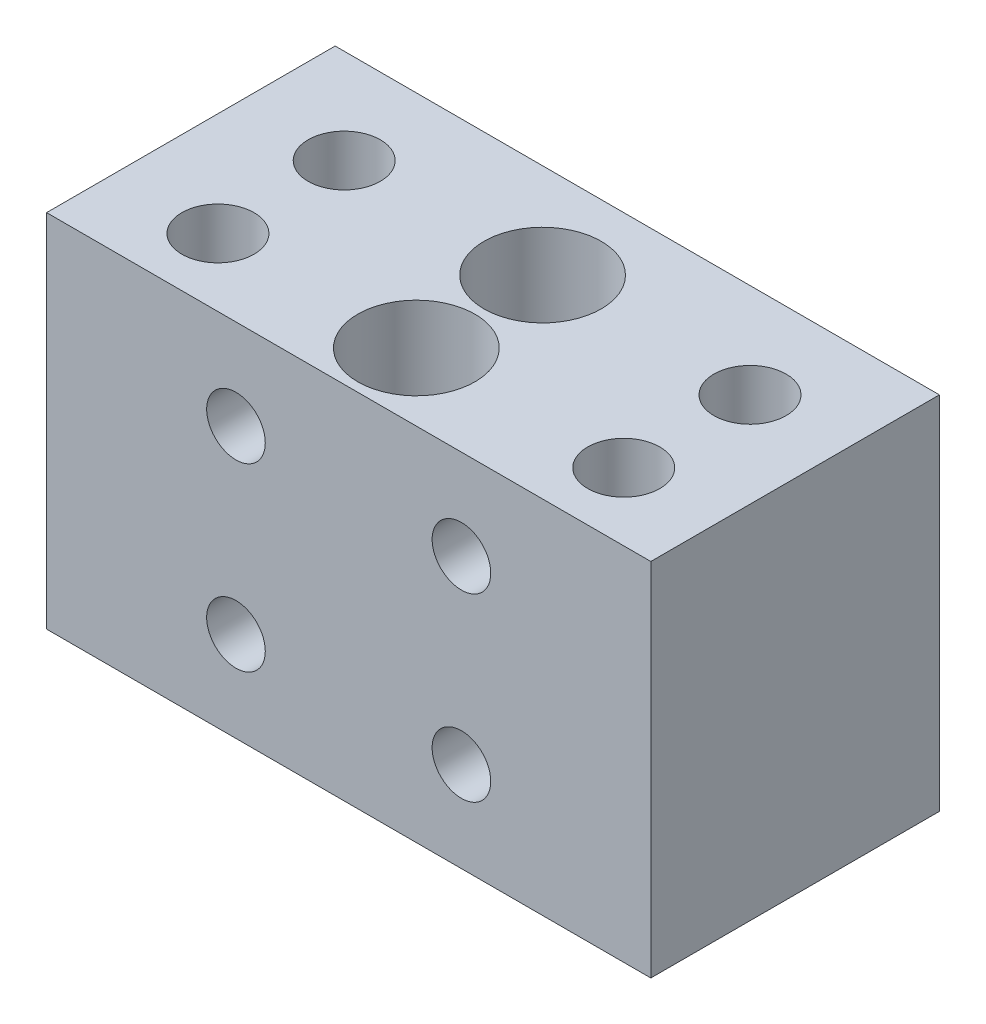
from build123d import *

# Parameters (mm, degrees)
SKETCH1_W                      = 67
SKETCH1_H                      = 40
BOSS_EXTRUDE1_DEPTH            = 32
SKETCH2_R                      = 6
CUT_EXTRUDE1_DEPTH             = 19
SKETCH4_R                      = 4
CUT_EXTRUDE2_DEPTH             = 22
LPATTERN1_COUNT                = 2
LPATTERN1_PITCH                = 45
LPATTERN1_COUNT_DIR2           = 2
LPATTERN1_PITCH_DIR2           = 14
SKETCH5_R                      = 6.5
CUT_EXTRUDE3_DEPTH             = 35
M4X0_7_TAPPED_HOLE1_D          = 3.3
CBORE_FOR_M3_SHCS1_D           = 3.4
CBORE_FOR_M3_SHCS1_CBORE_D     = 6.5
CBORE_FOR_M3_SHCS1_CBORE_DEPTH = 30
LPATTERN2_COUNT                = 2
LPATTERN2_PITCH                = 25
LPATTERN2_COUNT_DIR2           = 2
LPATTERN2_PITCH_DIR2           = 20
M3X0_5_TAPPED_HOLE1_D          = 2.5
M3X0_5_TAPPED_HOLE1_DEPTH      = 5.5
M3X0_5_TAPPED_HOLE1_TIP        = 0.751075774


with BuildPart() as part:
    # Sketch1 → Boss-Extrude1 (new body)
    with BuildSketch(Plane.XY):
        with Locations((33.5, 20)):
            Rectangle(SKETCH1_W, SKETCH1_H)
    extrude(amount=BOSS_EXTRUDE1_DEPTH)

    # Sketch2 → Cut-Extrude1 (cut)
    with BuildSketch(Plane.XZ):
        with Locations((11.5, 24.5)):
            Circle(SKETCH2_R)
    cut_extrude1 = extrude(amount=-CUT_EXTRUDE1_DEPTH, mode=Mode.SUBTRACT)

    # Sketch4 → Cut-Extrude2 (cut, through all)
    with BuildSketch(Plane.XZ.offset(-19)):
        with Locations((11.5, 24.5)):
            Circle(SKETCH4_R)
    cut_extrude2 = extrude(amount=-CUT_EXTRUDE2_DEPTH, mode=Mode.SUBTRACT)

    # LPattern1: Cut-Extrude1, Cut-Extrude2 2 × 2
    with Locations(*[(i * LPATTERN1_PITCH, 0, -j * LPATTERN1_PITCH_DIR2) for i in range(LPATTERN1_COUNT) for j in range(LPATTERN1_COUNT_DIR2) if (i, j) != (0, 0)]):
        add(cut_extrude1, mode=Mode.SUBTRACT)
        add(cut_extrude2, mode=Mode.SUBTRACT)

    # Sketch5 → Cut-Extrude3 (cut)
    with BuildSketch(Plane(origin=(0, 40, 0), x_dir=(1, 0, 0), z_dir=(0, 1, 0))):
        with Locations((33.5, -10.5)):
            Circle(SKETCH5_R)
        with Locations((33.5, -24.5)):
            Circle(SKETCH5_R)
    extrude(amount=-CUT_EXTRUDE3_DEPTH, mode=Mode.SUBTRACT)

    # M4x0.7 Tapped Hole1 (through all)
    with Locations(Plane(origin=(0, 5, 0), x_dir=(1, 0, 0), z_dir=(0, 1, 0))):
        with Locations((33.5, -24.5), (33.5, -10.5)):
            Hole(M4X0_7_TAPPED_HOLE1_D / 2)

    # CBORE for M3 SHCS1 (through all)
    with Locations(Plane.XY.offset(32)):
        with Locations((21, 30)):
            cbore_for_m3_shcs1 = CounterBoreHole(CBORE_FOR_M3_SHCS1_D / 2, CBORE_FOR_M3_SHCS1_CBORE_D / 2, CBORE_FOR_M3_SHCS1_CBORE_DEPTH)

    # LPattern2: CBORE for M3 SHCS1 2 × 2
    with Locations(*[(i * LPATTERN2_PITCH, -j * LPATTERN2_PITCH_DIR2, 0) for i in range(LPATTERN2_COUNT) for j in range(LPATTERN2_COUNT_DIR2) if (i, j) != (0, 0)]):
        add(cbore_for_m3_shcs1, mode=Mode.SUBTRACT)

    # M3x0.5 Tapped Hole1
    with Locations(Plane(origin=(0, 0, 0), x_dir=(-1, 0, 0), z_dir=(0, -1, 0))):
        with Locations((-45.5, -17.5), (-21.5, -17.5)):
            Hole(M3X0_5_TAPPED_HOLE1_D / 2, depth=M3X0_5_TAPPED_HOLE1_DEPTH)
            with Locations((0, 0, -(M3X0_5_TAPPED_HOLE1_DEPTH + M3X0_5_TAPPED_HOLE1_TIP / 2))):  # 118° drill point
                Cone(0, M3X0_5_TAPPED_HOLE1_D / 2, M3X0_5_TAPPED_HOLE1_TIP, mode=Mode.SUBTRACT)


solid = part.part
